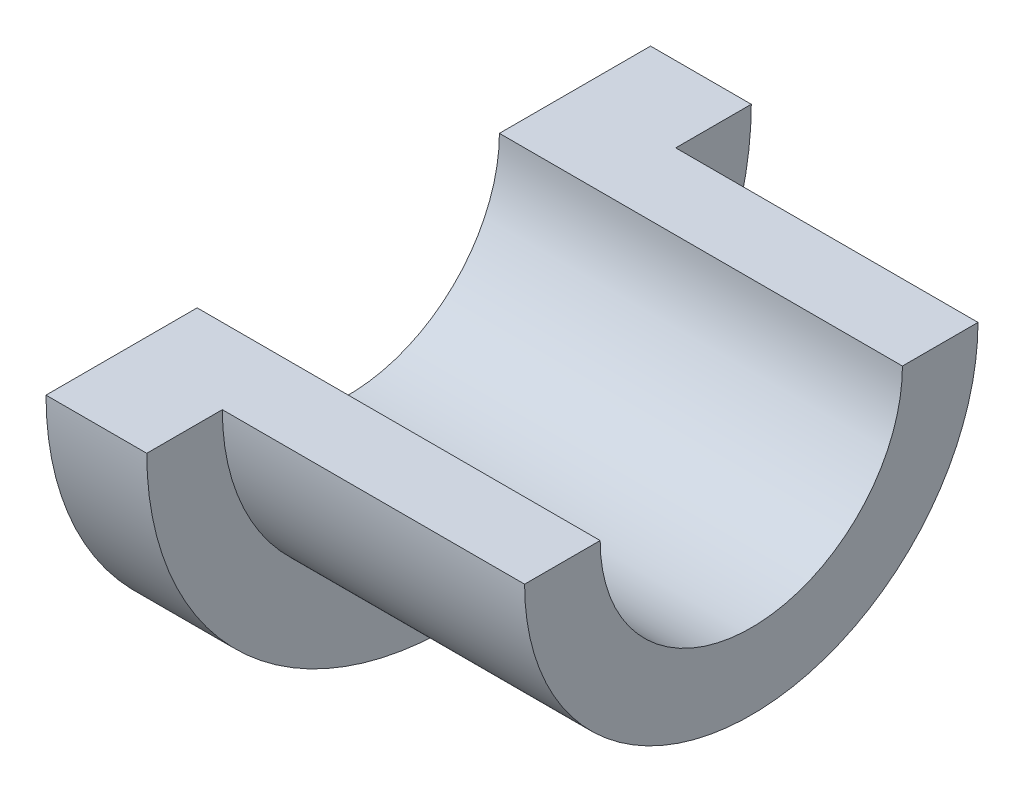
from build123d import *

# Parameters (mm, degrees)
SKETCH1_R           = 6
BOSS_EXTRUDE1_DEPTH = 2
SKETCH2_R           = 4.5
BOSS_EXTRUDE2_DEPTH = 6
SKETCH3_R           = 3
CUT_EXTRUDE1_DEPTH  = 11
SKETCH4_W           = 17.898398612
SKETCH4_H           = 8.444372679
CUT_EXTRUDE2_DEPTH  = 11


with BuildPart() as part:
    # Sketch1 → Boss-Extrude1 (new body)
    with BuildSketch(Plane(origin=(0, 0, 0), x_dir=(0, 0, -1), z_dir=(1, 0, 0))):
        with Locations((-10.366970779, 4.315662044)):
            Circle(SKETCH1_R)
    extrude(amount=BOSS_EXTRUDE1_DEPTH)

    # Sketch2 → Boss-Extrude2 (add)
    with BuildSketch(Plane(origin=(2, 0, 0), x_dir=(0, 0, -1), z_dir=(1, 0, 0))):
        with Locations((-10.366970779, 4.315662044)):
            Circle(SKETCH2_R)
    extrude(amount=BOSS_EXTRUDE2_DEPTH)

    # Sketch3 → Cut-Extrude1 (cut)
    with BuildSketch(Plane(origin=(8, 0, 0), x_dir=(0, 0, -1), z_dir=(1, 0, 0))):
        with Locations((-10.366970779, 4.315662044)):
            Circle(SKETCH3_R)
    extrude(amount=-CUT_EXTRUDE1_DEPTH, mode=Mode.SUBTRACT)

    # Sketch4 → Cut-Extrude2 (cut)
    with BuildSketch(Plane(origin=(8, 0, 0), x_dir=(0, 0, -1), z_dir=(1, 0, 0))):
        with Locations((-9.724464162, 8.537848384)):
            Rectangle(SKETCH4_W, SKETCH4_H)
    extrude(amount=-CUT_EXTRUDE2_DEPTH, mode=Mode.SUBTRACT)


solid = part.part
